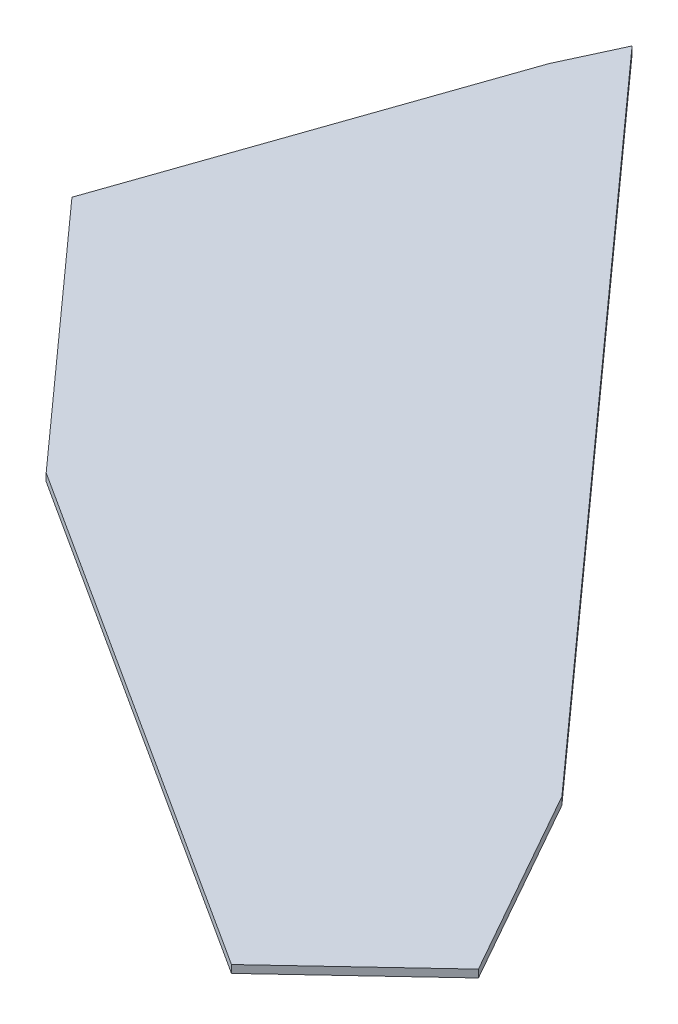
from build123d import *

# Parameters (mm, degrees)
BOSS_EXTRU_1_DEPTH = 2


with BuildPart() as part:
    # Esquisse1 → Boss.-Extru.1 (new body)
    with BuildSketch(Plane(origin=(0, 0, 0), x_dir=(1, 0, 0), z_dir=(0, 1, 0))):
        Polygon((-26.848083334, 157.791490328), (-58.822203261, 65.53706895), (0, 0), (135.077099652, -86.798891375), (168.284361453, -55.674377676), (140.224514958, -5.87243991), (-19.444386043, 172.023510836), (-20.021346405, 172.579626327), align=None)
    extrude(amount=BOSS_EXTRU_1_DEPTH)


solid = part.part
